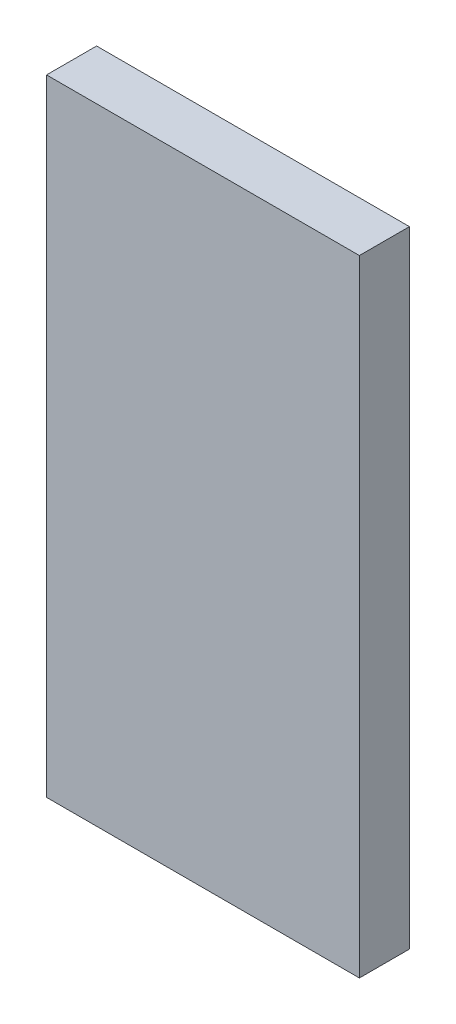
from build123d import *

# Parameters (mm, degrees)
SKETCH1_W           = 5
SKETCH1_H           = 10
BOSS_EXTRUDE1_DEPTH = 0.8


with BuildPart() as part:
    # Sketch1 → Boss-Extrude1 (new body)
    with BuildSketch(Plane.XY):
        Rectangle(SKETCH1_W, SKETCH1_H)
    extrude(amount=BOSS_EXTRUDE1_DEPTH)


solid = part.part
